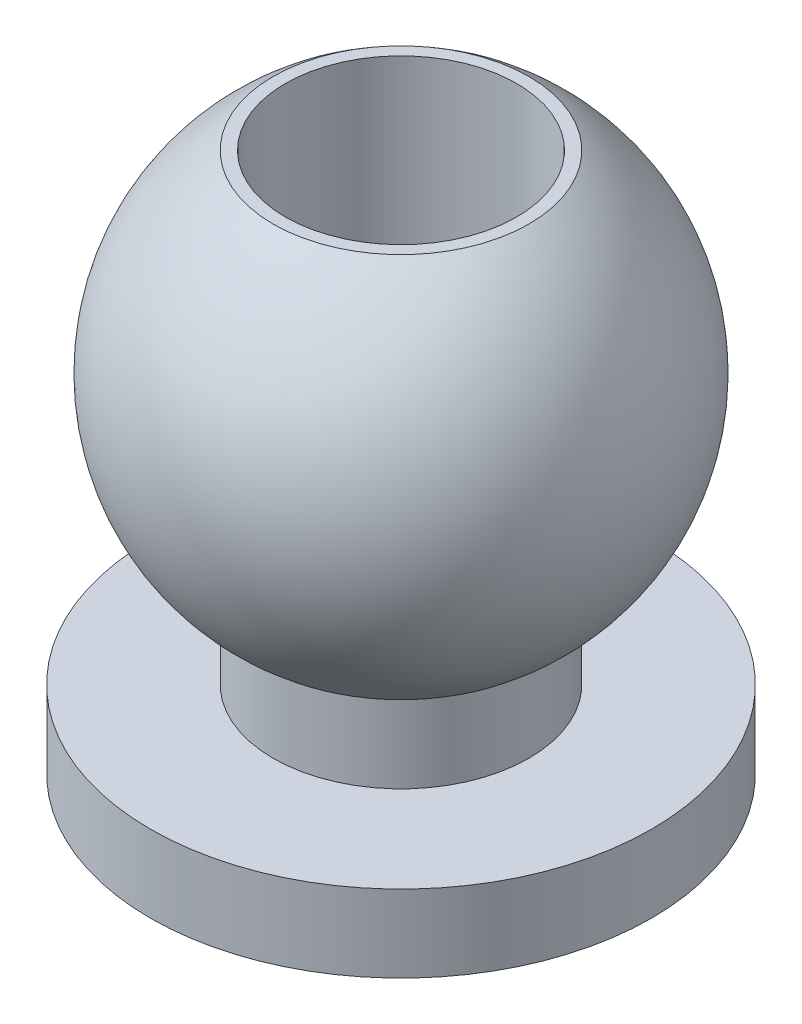
from build123d import *

# Parameters (mm, degrees)
SKETCH2_R          = 1.5
CUT_EXTRUDE1_DEPTH = 8


with BuildPart() as part:
    # Sketch1 → Revolve1 (revolve)
    with BuildSketch(Plane.XY):
        with BuildLine():
            Line((0, 0), (-3.25, 0))
            Line((-3.25, 0), (-3.25, 1))
            Line((-3.25, 1), (-1.658312395, 1))
            Line((-1.658312395, 1), (-1.658312395, 2))
            ThreePointArc((-1.658312395, 2), (-3, 4.5), (-1.658312395, 7))
            Line((-1.658312395, 7), (0, 7))
            Line((0, 7), (0, 0))
        make_face()
    revolve(axis=Axis((0, 0, 0), (0, 1, 0)))

    # Sketch2 → Cut-Extrude1 (cut, through all)
    with BuildSketch(Plane(origin=(0, 7, 0), x_dir=(1, 0, 0), z_dir=(0, 1, 0))):
        Circle(SKETCH2_R)
    extrude(amount=-CUT_EXTRUDE1_DEPTH, mode=Mode.SUBTRACT)


solid = part.part
